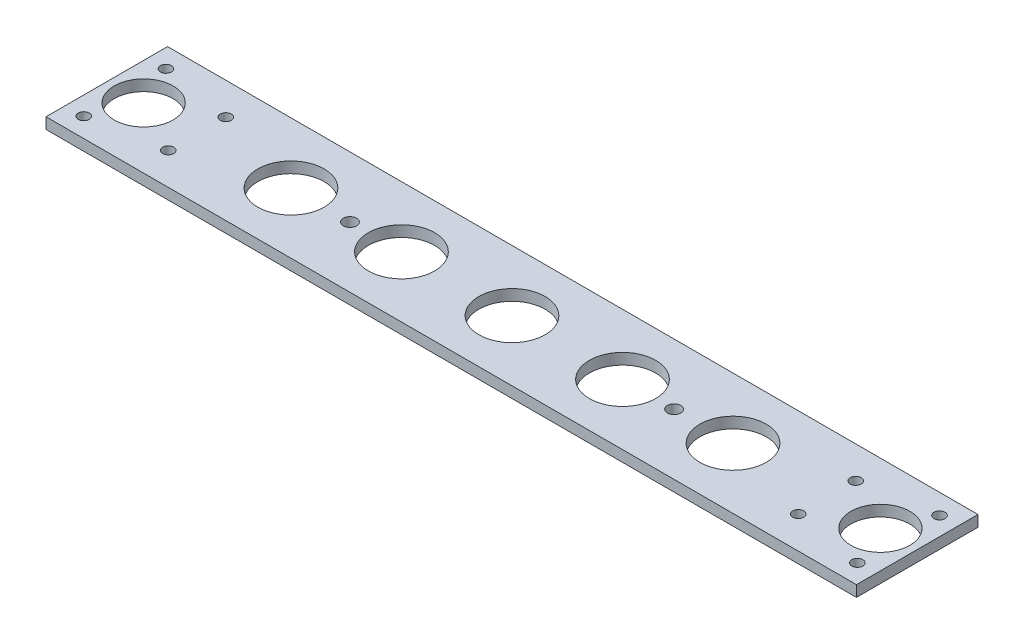
from build123d import *

# Parameters (mm, degrees)
SKETCH_1_W      = 220
SKETCH_1_H      = 33
SKETCH_1_R      = 1.5
SKETCH_1_R_2    = 9
SKETCH_1_R_3    = 8
SKETCH_1_R_4    = 1.8
EXTRUDE_1_DEPTH = 3


with BuildPart() as part:
    # 草图1 → 凸台-拉伸1 (new body)
    with BuildSketch(Plane(origin=(0, 0, 0), x_dir=(1, 0, 0), z_dir=(0, 1, 0))):
        with Locations((110, -16.5)):
            Rectangle(SKETCH_1_W, SKETCH_1_H)
        with Locations((5, -27.75)):
            Circle(SKETCH_1_R, mode=Mode.SUBTRACT)
        with Locations((5, -5.45)):
            Circle(SKETCH_1_R, mode=Mode.SUBTRACT)
        with Locations((24.5, -8.7)):
            Circle(SKETCH_1_R, mode=Mode.SUBTRACT)
        with Locations((24.5, -24.3)):
            Circle(SKETCH_1_R, mode=Mode.SUBTRACT)
        with Locations((195.5, -8.7)):
            Circle(SKETCH_1_R, mode=Mode.SUBTRACT)
        with Locations((195.5, -24.3)):
            Circle(SKETCH_1_R, mode=Mode.SUBTRACT)
        with Locations((215, -27.75)):
            Circle(SKETCH_1_R, mode=Mode.SUBTRACT)
        with Locations((215, -5.45)):
            Circle(SKETCH_1_R, mode=Mode.SUBTRACT)
        with Locations((110, -16.5)):
            Circle(SKETCH_1_R_2, mode=Mode.SUBTRACT)
        with Locations((140, -16.5)):
            Circle(SKETCH_1_R_2, mode=Mode.SUBTRACT)
        with Locations((10, -16.5)):
            Circle(SKETCH_1_R_3, mode=Mode.SUBTRACT)
        with Locations((210, -16.5)):
            Circle(SKETCH_1_R_3, mode=Mode.SUBTRACT)
        with Locations((170, -16.5)):
            Circle(SKETCH_1_R_2, mode=Mode.SUBTRACT)
        with Locations((80, -16.5)):
            Circle(SKETCH_1_R_2, mode=Mode.SUBTRACT)
        with Locations((50, -16.5)):
            Circle(SKETCH_1_R_2, mode=Mode.SUBTRACT)
        with Locations((154, -16.5)):
            Circle(SKETCH_1_R_4, mode=Mode.SUBTRACT)
        with Locations((66, -16.5)):
            Circle(SKETCH_1_R_4, mode=Mode.SUBTRACT)
    extrude(amount=EXTRUDE_1_DEPTH)


solid = part.part
